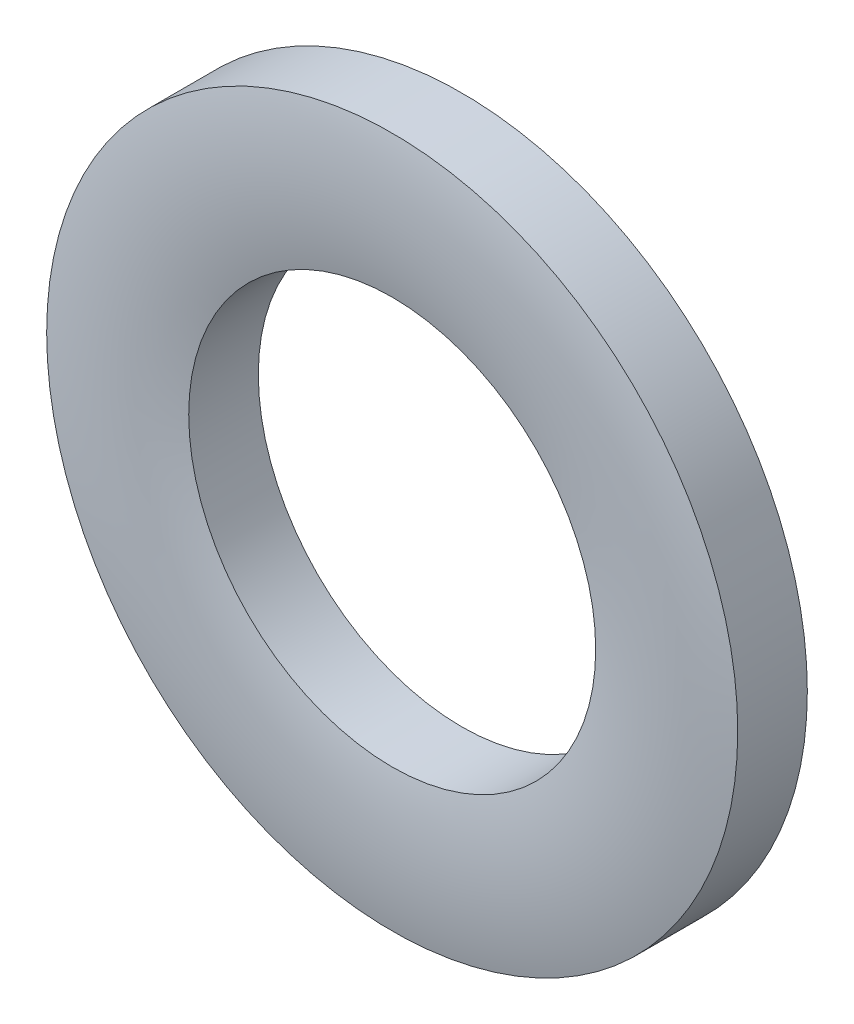
from build123d import *


with BuildPart() as part:
    # Sketch3 → Revolve1 (revolve)
    with BuildSketch(Plane(origin=(0, 0, 0), x_dir=(0, 0, -1), z_dir=(1, 0, 0))):
        with BuildLine():
            Line((0.5, 4.5), (-0.4063, 4.5))
            ThreePointArc((-0.4063, 4.5), (-0.5, 3.575), (-0.4063, 2.65))
            Line((-0.4063, 2.65), (0.5, 2.65))
            Line((0.5, 2.65), (0.5, 4.5))
        make_face()
    revolve(axis=Axis((0, 0, 0.5), (0, 0, -1)))


solid = part.part
